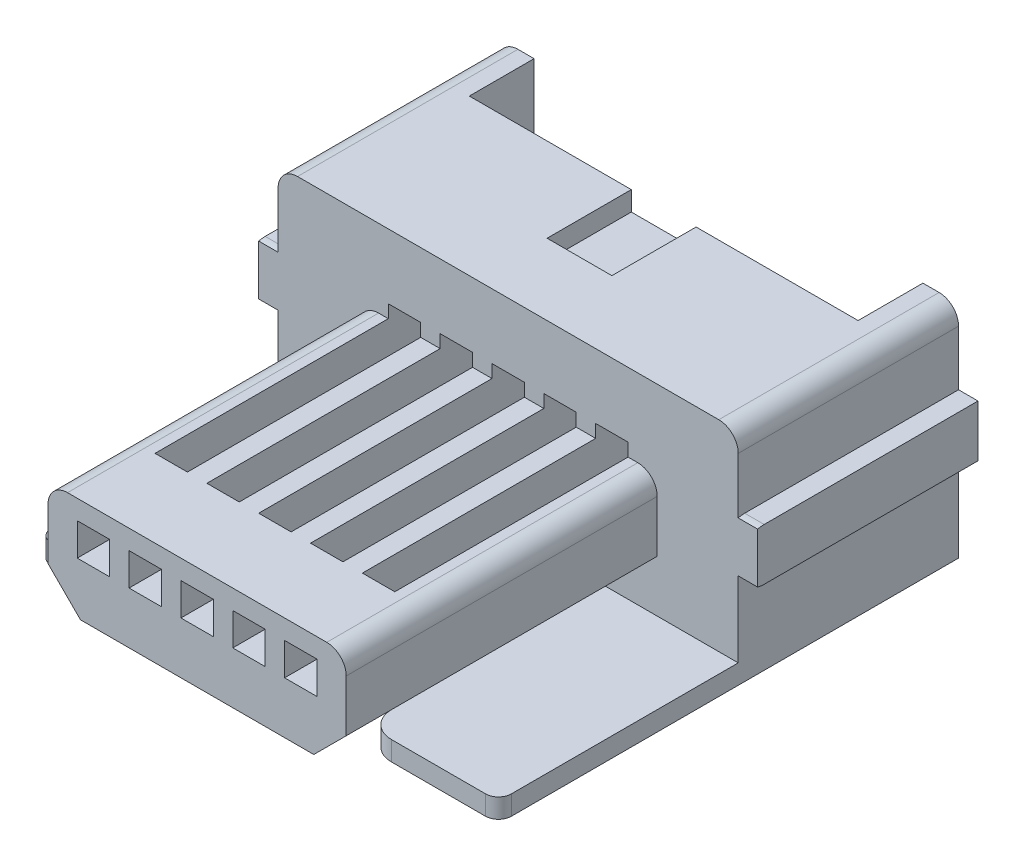
from build123d import *

# Parameters (mm, degrees)
BOSS_EXTRUDE1_DEPTH = 8.2
BOSS_EXTRUDE2_DEPTH = 3.85
SKETCH3_OUTSIDE_W   = 12.05
SKETCH3_OUTSIDE_H   = 7.75
CUT_EXTRUDE1_DEPTH  = 4.8
SKETCH4_W           = 1
SKETCH4_H           = 0.3
CUT_EXTRUDE3_DEPTH  = 2.3
CUT_EXTRUDE6_DEPTH  = 4.4
SKETCH6_W           = 0.5
SKETCH6_H           = 0.5
CUT_EXTRUDE7_DEPTH  = 2
SKETCH7_W           = 0.5
SKETCH7_H           = 0.8
CUT_EXTRUDE8_DEPTH  = 7
SKETCH8_W           = 6
SKETCH8_H           = 1
CUT_EXTRUDE9_DEPTH  = 2
SKETCH9_W           = 6
SKETCH9_H           = 0.5
CUT_EXTRUDE10_DEPTH = 1
SKETCH10_R          = 0.4
BOSS_EXTRUDE3_DEPTH = 1.1
CHAMFER1_SIZE       = 0.2
SKETCH11_W          = 7.1
SKETCH11_H          = 0.3
BOSS_EXTRUDE4_DEPTH = 3.7
FILLET1_R           = 0.2
SKETCH12_W          = 3
SKETCH12_H          = 2
CUT_EXTRUDE11_DEPTH = 0.5
FILLET2_R           = 0.2
FILLET3_R           = 0.4


with BuildPart() as part:
    # Sketch1 → Boss-Extrude1 (new body)
    with BuildSketch(Plane.XY):
        with BuildLine():
            Line((-3.25, 3.4), (3.25, 3.4))
            ThreePointArc((3.25, 3.4), (3.462132034, 3.312132034), (3.55, 3.1))
            Line((3.55, 3.1), (3.55, 0))
            Line((3.55, 0), (-3.55, 0))
            Line((-3.55, 0), (-3.55, 3.1))
            ThreePointArc((-3.55, 3.1), (-3.462132034, 3.312132034), (-3.25, 3.4))
        make_face()
    extrude(amount=BOSS_EXTRUDE1_DEPTH)

    # Sketch2 → Boss-Extrude2 (add, symmetric)
    with BuildSketch(Plane(origin=(0, 0, 0), x_dir=(0, 0, -1), z_dir=(1, 0, 0))):
        with BuildLine():
            Line((0, 2.25), (-3.3, 2.25))
            ThreePointArc((-3.3, 2.25), (-3.7, 1.85), (-3.3, 1.45))
            Line((-3.3, 1.45), (0, 1.45))
            Line((0, 1.45), (0, 2.25))
        make_face()
    extrude(amount=BOSS_EXTRUDE2_DEPTH, both=True)

    # Sketch3 outside → Cut-Extrude1 (cut)
    with BuildSketch(Plane.XY.offset(8.2)):
        with Locations((0, 1.7)):
            Rectangle(SKETCH3_OUTSIDE_W, SKETCH3_OUTSIDE_H)
        with BuildLine():
            Line((-2, 2.2), (2, 2.2))
            ThreePointArc((2, 2.2), (2.212132034, 2.112132034), (2.3, 1.9))
            Line((2.3, 1.9), (2.3, 1.1))
            Line((2.3, 1.1), (1.8, 0.6))
            Line((1.8, 0.6), (-1.8, 0.6))
            Line((-1.8, 0.6), (-2.3, 1.1))
            Line((-2.3, 1.1), (-2.3, 1.9))
            ThreePointArc((-2.3, 1.9), (-2.212132034, 2.112132034), (-2, 2.2))
        make_face(mode=Mode.SUBTRACT)
    extrude(amount=-CUT_EXTRUDE1_DEPTH, mode=Mode.SUBTRACT)

    # Sketch4 → Cut-Extrude3 (cut)
    with BuildSketch(Plane.XY):
        with Locations((0, 3.25)):
            Rectangle(SKETCH4_W, SKETCH4_H)
    extrude(amount=CUT_EXTRUDE3_DEPTH, mode=Mode.SUBTRACT)

    # Sketch5 → Cut-Extrude6 (cut, through all)
    with BuildSketch(Plane(origin=(0, 0, 0), x_dir=(1, 0, 0), z_dir=(0, 1, 0))):
        Polygon((-1.85, 0), (1.85, 0), (1.85, -1), (1.35, -1), (1.35, -0.7), (1.05, -0.7), (1.05, -1), (0.55, -1), (0.55, -0.7), (0.25, -0.7), (0.25, -1), (-0.25, -1), (-0.25, -0.7), (-0.55, -0.7), (-0.55, -1), (-1.05, -1), (-1.05, -0.7), (-1.35, -0.7), (-1.35, -1), (-1.85, -1), align=None)
    extrude(amount=CUT_EXTRUDE6_DEPTH, mode=Mode.SUBTRACT)

    # Sketch6 → Cut-Extrude7 (cut)
    with BuildSketch(Plane.XY.offset(8.2)):
        with Locations((1.6, 1.65)):
            Rectangle(SKETCH6_W, SKETCH6_H)
        with Locations((0.8, 1.65)):
            Rectangle(SKETCH6_W, SKETCH6_H)
        with Locations((0, 1.65)):
            Rectangle(SKETCH6_W, SKETCH6_H)
        with Locations((-0.8, 1.65)):
            Rectangle(SKETCH6_W, SKETCH6_H)
        with Locations((-1.6, 1.65)):
            Rectangle(SKETCH6_W, SKETCH6_H)
    extrude(amount=-CUT_EXTRUDE7_DEPTH, mode=Mode.SUBTRACT)

    # Sketch7 → Cut-Extrude8 (cut)
    with BuildSketch(Plane.XY):
        with Locations((1.6, 2)):
            Rectangle(SKETCH7_W, SKETCH7_H)
        with Locations((0.8, 2)):
            Rectangle(SKETCH7_W, SKETCH7_H)
        with Locations((0, 2)):
            Rectangle(SKETCH7_W, SKETCH7_H)
        with Locations((-0.8, 2)):
            Rectangle(SKETCH7_W, SKETCH7_H)
        with Locations((-1.6, 2)):
            Rectangle(SKETCH7_W, SKETCH7_H)
    extrude(amount=CUT_EXTRUDE8_DEPTH, mode=Mode.SUBTRACT)

    # Sketch8 → Cut-Extrude9 (cut)
    with BuildSketch(Plane(origin=(0, 3.4, 0), x_dir=(1, 0, 0), z_dir=(0, 1, 0))):
        with Locations((0, -0.5)):
            Rectangle(SKETCH8_W, SKETCH8_H)
    extrude(amount=-CUT_EXTRUDE9_DEPTH, mode=Mode.SUBTRACT)

    # Sketch9 → Cut-Extrude10 (cut)
    with BuildSketch(Plane.XY):
        with Locations((0, 0.25)):
            Rectangle(SKETCH9_W, SKETCH9_H)
    extrude(amount=CUT_EXTRUDE10_DEPTH, mode=Mode.SUBTRACT)

    # Sketch10 → Boss-Extrude3 (add)
    with BuildSketch(Plane.XZ):
        with Locations((2.2, 3.05)):
            Circle(SKETCH10_R)
        with Locations((-2.2, 3.05)):
            Circle(SKETCH10_R)
    extrude(amount=BOSS_EXTRUDE3_DEPTH)

    # Chamfer1
    chamfer1_edges = [part.edges().sort_by_distance(p)[0] for p in [
        (1.8, -1.1, 3.05),
        (-2.6, -1.1, 3.05),
    ]]
    chamfer(chamfer1_edges, length=CHAMFER1_SIZE)

    # Sketch11 → Boss-Extrude4 (add)
    with BuildSketch(Plane.XY.offset(3.4)):
        with Locations((0, 0.15)):
            Rectangle(SKETCH11_W, SKETCH11_H)
    extrude(amount=BOSS_EXTRUDE4_DEPTH)

    # Fillet1
    fillet1_edges = [part.edges().sort_by_distance(p)[0] for p in [
        (-3.55, 0.15, 7.1),
        (3.55, 0.15, 7.1),
    ]]
    fillet(fillet1_edges, radius=FILLET1_R)

    # Sketch12 → Cut-Extrude11 (cut)
    with BuildSketch(Plane.XZ):
        with Locations((0, 6.1)):
            Rectangle(SKETCH12_W, SKETCH12_H)
    extrude(amount=-CUT_EXTRUDE11_DEPTH, mode=Mode.SUBTRACT)

    # Fillet2
    fillet2_edges = [part.edges().sort_by_distance(p)[0] for p in [
        (1.5, 0.15, 5.1),
        (-1.5, 0.15, 5.1),
    ]]
    fillet(fillet2_edges, radius=FILLET2_R)

    # Fillet3
    fillet3_edges = [part.edges().sort_by_distance(p)[0] for p in [
        (1.5, 0.15, 7.1),
        (-1.5, 0.15, 7.1),
    ]]
    fillet(fillet3_edges, radius=FILLET3_R)


solid = part.part
